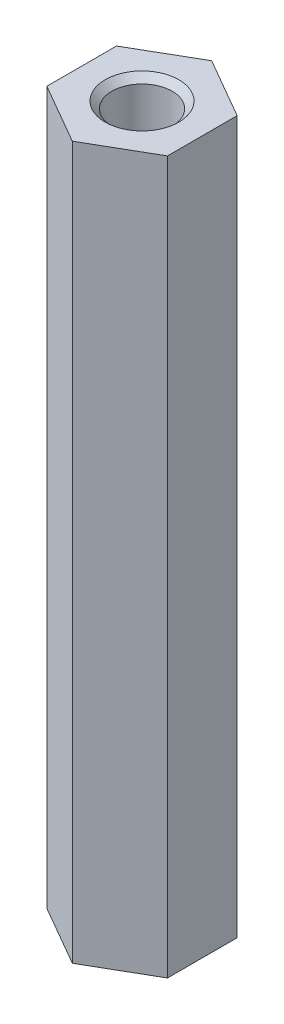
from build123d import *

# Parameters (mm, degrees)
BOSS_EXTRUDE1_DEPTH         = 29.5
M3_TAPPED_HOLE1_D           = 2.5
M3_TAPPED_HOLE1_DEPTH       = 7.5
M3_TAPPED_HOLE1_CSINK_D     = 3.05
M3_TAPPED_HOLE1_CSINK_ANGLE = 90
M3_TAPPED_HOLE1_TIP         = 0.751075774
M3_TAPPED_HOLE2_D           = 2.5
M3_TAPPED_HOLE2_DEPTH       = 7.5
M3_TAPPED_HOLE2_CSINK_D     = 3.05
M3_TAPPED_HOLE2_CSINK_ANGLE = 90
M3_TAPPED_HOLE2_TIP         = 0.751075774


with BuildPart() as part:
    # Sketch1 → Boss-Extrude1 (new body)
    with BuildSketch(Plane(origin=(0, 0, 0), x_dir=(1, 0, 0), z_dir=(0, 1, 0))):
        Polygon((-2.5, 1.443375673), (-2.5, -1.443375673), (0, -2.886751346), (2.5, -1.443375673), (2.5, 1.443375673), (0, 2.886751346), align=None)
    extrude(amount=BOSS_EXTRUDE1_DEPTH)

    # M3 Tapped Hole1
    with Locations(Plane(origin=(0, 29.5, 0), x_dir=(1, 0, 0), z_dir=(0, 1, 0))):
        with Locations((0, 0)):
            CounterSinkHole(M3_TAPPED_HOLE1_D / 2, M3_TAPPED_HOLE1_CSINK_D / 2, depth=M3_TAPPED_HOLE1_DEPTH, counter_sink_angle=M3_TAPPED_HOLE1_CSINK_ANGLE)
            with Locations((0, 0, -(M3_TAPPED_HOLE1_DEPTH + M3_TAPPED_HOLE1_TIP / 2))):  # 118° drill point
                Cone(0, M3_TAPPED_HOLE1_D / 2, M3_TAPPED_HOLE1_TIP, mode=Mode.SUBTRACT)

    # M3 Tapped Hole2
    with Locations(Plane(origin=(0, 0, 0), x_dir=(-1, 0, 0), z_dir=(0, -1, 0))):
        with Locations((0, 0)):
            CounterSinkHole(M3_TAPPED_HOLE2_D / 2, M3_TAPPED_HOLE2_CSINK_D / 2, depth=M3_TAPPED_HOLE2_DEPTH, counter_sink_angle=M3_TAPPED_HOLE2_CSINK_ANGLE)
            with Locations((0, 0, -(M3_TAPPED_HOLE2_DEPTH + M3_TAPPED_HOLE2_TIP / 2))):  # 118° drill point
                Cone(0, M3_TAPPED_HOLE2_D / 2, M3_TAPPED_HOLE2_TIP, mode=Mode.SUBTRACT)


solid = part.part
